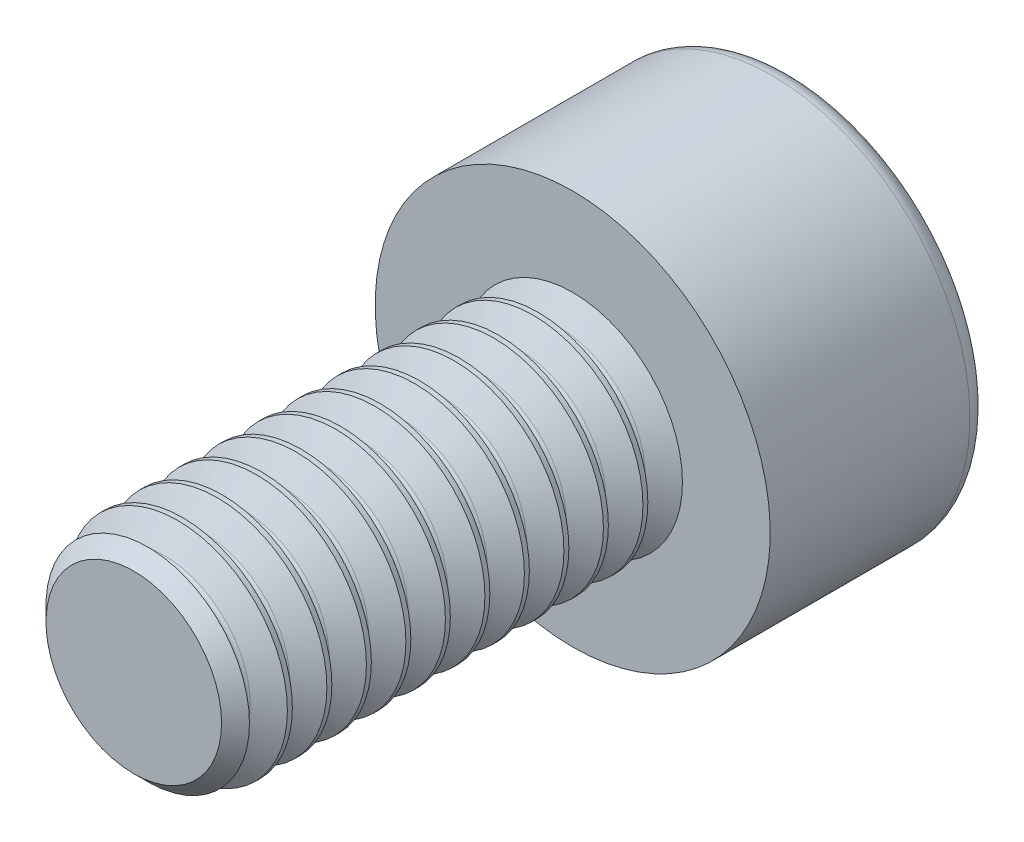
from build123d import *

# Parameters (mm, degrees)
SKETCH5_W           = 5
SKETCH5_H           = 1.25
THREAD_SIMPLE_COUNT = 12
THREAD_SIMPLE_PITCH = 0.45
SKETCH15_W          = 2.5
SKETCH15_H          = 2.25
CUT_HEAD_KEY_DEPTH  = 1.25


with BuildPart() as part:
    # Sketch5 → body (revolve)
    with BuildSketch(Plane(origin=(0, 0, 0), x_dir=(0, 0, -1), z_dir=(1, 0, 0))):
        with Locations((-2.5, 0.625)):
            Rectangle(SKETCH5_W, SKETCH5_H)
    revolve(axis=Axis((0, 0, 5), (0, 0, -1)))

    # Sketch11 → cut-chamfer-start (revolve, cut)
    with BuildSketch(Plane(origin=(0, 0, 0), x_dir=(0, 0, -1), z_dir=(1, 0, 0))):
        Polygon((-5, -1.25), (-5, -1), (-4.75, -1.25), align=None)
    revolve(axis=Axis((0, 0, 5), (0, 0, -1)), mode=Mode.SUBTRACT)

    # Sketch8 → thread-single (revolve, cut)
    with BuildSketch(Plane(origin=(0, 0, 0), x_dir=(0, 0, -1), z_dir=(1, 0, 0))):
        with BuildLine():
            Line((-0.39375, -1.25), (0, -1.25))
            Line((0, -1.25), (-0.1546875, -0.982073391))
            ThreePointArc((-0.1546875, -0.982073391), (-0.196875, -0.957716426), (-0.2390625, -0.982073391))
            Line((-0.2390625, -0.982073391), (-0.39375, -1.25))
        make_face()
    thread_single = revolve(axis=Axis((0, 0, 5), (0, 0, -1)), mode=Mode.SUBTRACT)

    # thread-simple: thread-single ×12
    with Locations(*[(0, 0, i * THREAD_SIMPLE_PITCH) for i in range(1, THREAD_SIMPLE_COUNT)]):
        add(thread_single, mode=Mode.SUBTRACT)

    # Sketch15 → body-head (revolve)
    with BuildSketch(Plane(origin=(0, 0, 0), x_dir=(0, 0, -1), z_dir=(1, 0, 0))):
        with Locations((1.25, -1.125)):
            Rectangle(SKETCH15_W, SKETCH15_H)
    revolve(axis=Axis((0, 0, -2.5), (0, 0, 1)))

    # Sketch19 → cut-head-profile (revolve, cut)
    with BuildSketch(Plane(origin=(0, 0, 0), x_dir=(0, 0, -1), z_dir=(1, 0, 0))):
        with BuildLine():
            Line((2.5, -2.25), (2.5, -2.025))
            ThreePointArc((2.5, -2.025), (2.434099026, -2.184099026), (2.275, -2.25))
            Line((2.275, -2.25), (2.5, -2.25))
        make_face()
    revolve(axis=Axis((0, 0, -2.5), (0, 0, 1)), mode=Mode.SUBTRACT)

    # Sketch25 → cut-head-key (cut)
    with BuildSketch(Plane.XY.offset(-2.5)):
        Polygon((0.577350269, 1), (-0.577350269, 1), (-1.154700538, 0), (-0.577350269, -1), (0.577350269, -1), (1.154700538, 0), align=None)
    extrude(amount=CUT_HEAD_KEY_DEPTH, mode=Mode.SUBTRACT)


solid = part.part
